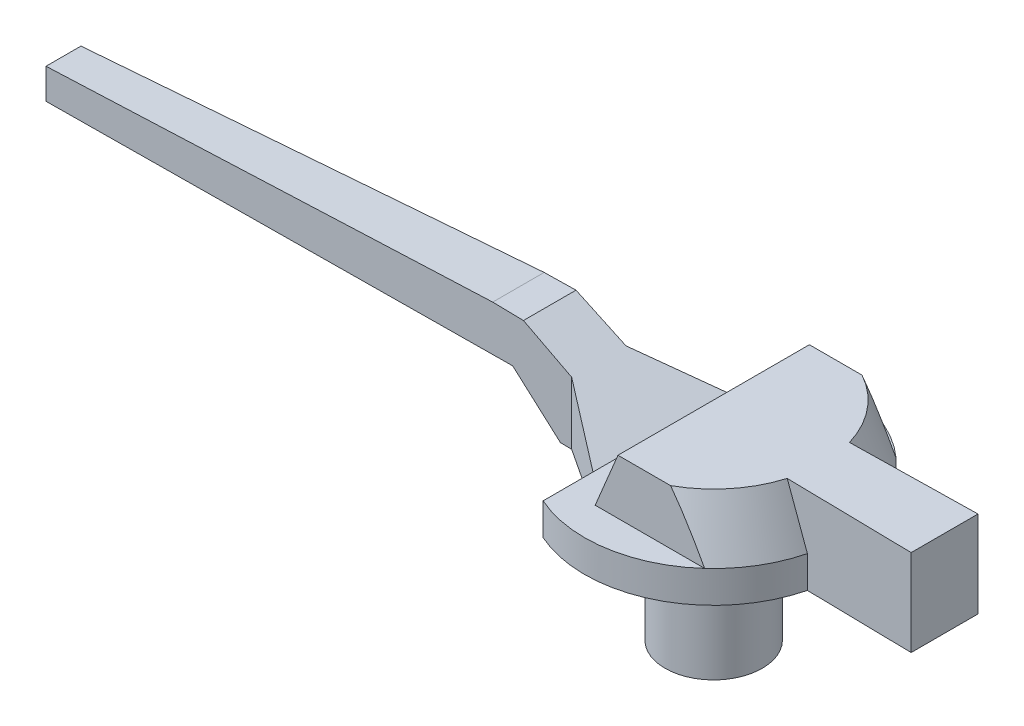
from build123d import *

# Parameters (mm, degrees)
EXTRUDE_1_DEPTH          = 2.85
SKETCH_3_OUTSIDE_W       = 37.198
SKETCH_3_OUTSIDE_H       = 16.698
SKETCH_3_OUTSIDE_W_2     = 45.46824203
SKETCH_3_OUTSIDE_H_2     = 6.3
CUT_EXTRUDE_1_DEPTH      = 1.8
CUT_EXTRUDE_2_DEPTH      = 8.4
CUT_EXTRUDE_4_DEPTH      = 2.8
CUT_EXTRUDE_4_DEPTH_BACK = 6.05


with BuildPart() as part:
    # Эскиз1 → Повернуть1 (revolve)
    with BuildSketch(Plane(origin=(0, 0, 0), x_dir=(0, 0, -1), z_dir=(1, 0, 0))):
        Polygon((-0.45, 0), (-1.6, 0), (-1.6, 4), (-4.25, 4), (-4.25, 5.05), (-3.594853578, 6.85), (0, 6.85), (0, 5), (-0.45, 5), align=None)
    revolve(axis=Axis((0, 0, 0), (0, -1, 0)))

    # Эскиз2 → Бобышка-Вытянуть1 (add)
    with BuildSketch(Plane(origin=(0, 6.85, 0), x_dir=(1, 0, 0), z_dir=(0, 1, 0))):
        Polygon((-21.4, -0.575), (-21.4, 0.575), (7.6, 1.1), (7.6, -1.1), align=None)
    extrude(amount=-EXTRUDE_1_DEPTH)

    # Эскиз3 outside → Вырез-Вытянуть1 (cut)
    with BuildSketch(Plane(origin=(0, 6.85, 0), x_dir=(1, 0, 0), z_dir=(0, 1, 0))):
        with Locations((-6.9, 0)):
            Rectangle(SKETCH_3_OUTSIDE_W, SKETCH_3_OUTSIDE_H)
        Rectangle(SKETCH_3_OUTSIDE_W_2, SKETCH_3_OUTSIDE_H_2, mode=Mode.SUBTRACT)
    extrude(amount=-CUT_EXTRUDE_1_DEPTH, mode=Mode.SUBTRACT)

    # Эскиз4 → Вырез-Вытянуть2 (cut, through all)
    with BuildSketch(Plane.XY.offset(3.15)):
        Polygon((0, 6.85), (-0.749299763, 5.05), (-1.732187129, 5.05), (-5.395285576, 6.85), align=None)
        Polygon((-6.4250568, 6.85), (-21.4, 5.95), (-21.4, 6.85), align=None)
        Polygon((-21.4, 4.95), (-5.756816797, 5.373014976), (-4.15637233, 4), (-21.4, 4), align=None)
    extrude(amount=-CUT_EXTRUDE_2_DEPTH, mode=Mode.SUBTRACT)

    # Эскиз5 → Вырез-Вытянуть4 (cut, two sides)
    with BuildSketch(Plane(origin=(0, 5.05, 0), x_dir=(1, 0, 0), z_dir=(0, 1, 0))) as cut_extrude_4_sk:
        Polygon((-1.732187129, 4.790977117), (-1.732187129, 2.23974472), (-3.779539394, 0.893991097), (-5.395285576, 0.86474052), (-3.779539394, 4.790977117), align=None)
        Polygon((-5.395285576, -0.86474052), (-3.779539394, -4.790977117), (-1.732187129, -4.790977117), (-1.732187129, -2.23974472), (-3.779539394, -0.893991097), align=None)
    extrude(amount=CUT_EXTRUDE_4_DEPTH, mode=Mode.SUBTRACT)
    extrude(cut_extrude_4_sk.sketch, amount=-CUT_EXTRUDE_4_DEPTH_BACK, mode=Mode.SUBTRACT)


solid = part.part
